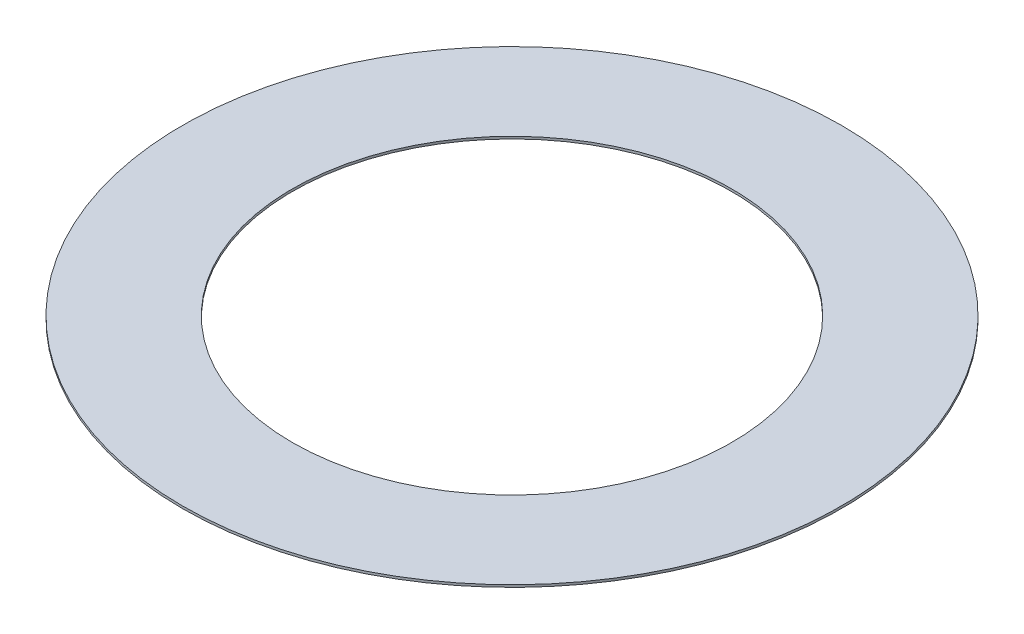
from build123d import *

# Parameters (mm, degrees)
SKETCH1_R           = 14.2875
BOSS_EXTRUDE1_DEPTH = 0.1016
SKETCH5_R           = 9.525
CUT_EXTRUDE1_DEPTH  = 1.1016


with BuildPart() as part:
    # Sketch1 → Boss-Extrude1 (new body)
    with BuildSketch(Plane(origin=(0, 0, 0), x_dir=(1, 0, 0), z_dir=(0, 1, 0))):
        Circle(SKETCH1_R)
    extrude(amount=BOSS_EXTRUDE1_DEPTH)

    # Sketch5 → Cut-Extrude1 (cut, through all)
    with BuildSketch(Plane(origin=(0, 0.1016, 0), x_dir=(-1, 0, 0), z_dir=(0, 1, 0))):
        Circle(SKETCH5_R)
    extrude(amount=-CUT_EXTRUDE1_DEPTH, mode=Mode.SUBTRACT)


solid = part.part
